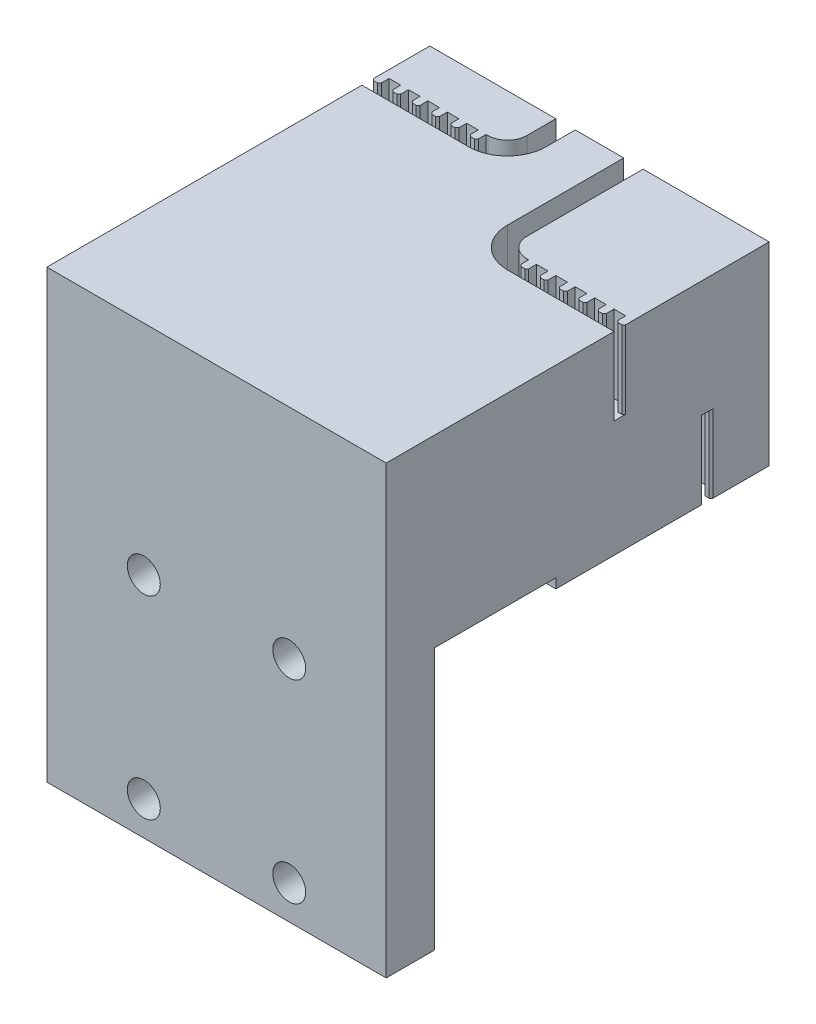
from build123d import *

# Parameters (mm, degrees)
SKETCH1_W           = 35
SKETCH1_H           = 22
BOSS_EXTRUDE1_DEPTH = 20
CUT_EXTRUDE1_DEPTH  = 8
CUT_EXTRUDE2_DEPTH  = 8
BOSS_EXTRUDE2_DEPTH = 8
BOSS_EXTRUDE4_DEPTH = 8
SKETCH9_W           = 35
SKETCH9_H           = 19
BOSS_EXTRUDE5_DEPTH = 12.5
SKETCH11_W          = 35
SKETCH11_H          = 46
BOSS_EXTRUDE6_DEPTH = 5
SKETCH12_R          = 1.7
CUT_EXTRUDE3_DEPTH  = 5


with BuildPart() as part:
    # Sketch1 → Boss-Extrude1 (new body)
    with BuildSketch(Plane(origin=(0, 0, 0), x_dir=(1, 0, 0), z_dir=(0, 1, 0))):
        with Locations((17.5, 11)):
            Rectangle(SKETCH1_W, SKETCH1_H)
    extrude(amount=BOSS_EXTRUDE1_DEPTH)

    # Sketch2 → Cut-Extrude1 (cut)
    with BuildSketch(Plane(origin=(0, 20, 0), x_dir=(1, 0, 0), z_dir=(0, 1, 0))):
        with BuildLine():
            Line((0, 15), (11, 15))
            ThreePointArc((11, 15), (13.828427125, 16.171572875), (15, 19))
            Line((15, 19), (15, 22))
            Line((15, 22), (13, 22))
            Line((13, 22), (13, 19))
            ThreePointArc((13, 19), (12.414213562, 17.585786438), (11, 17))
            Line((11, 17), (0, 17))
            Line((0, 17), (0, 15))
        make_face()
        with BuildLine():
            Line((35, 6), (24, 6))
            ThreePointArc((24, 6), (21.171572875, 7.171572875), (20, 10))
            Line((20, 10), (20, 22))
            Line((20, 22), (22, 22))
            Line((22, 22), (22, 10))
            ThreePointArc((22, 10), (22.585786438, 8.585786438), (24, 8))
            Line((24, 8), (35, 8))
            Line((35, 8), (35, 6))
        make_face()
    extrude(amount=-CUT_EXTRUDE1_DEPTH, mode=Mode.SUBTRACT)

    # Sketch5 → Cut-Extrude2 (cut)
    with BuildSketch(Plane(origin=(0, 0, 0), x_dir=(-1, 0, 0), z_dir=(0, -1, 0))):
        with BuildLine():
            Line((-35, 15), (-24, 15))
            ThreePointArc((-24, 15), (-21.171572875, 16.171572875), (-20, 19))
            Line((-20, 19), (-20, 22))
            Line((-20, 22), (-22, 22))
            Line((-22, 22), (-22, 19))
            ThreePointArc((-22, 19), (-22.585786438, 17.585786438), (-24, 17))
            Line((-24, 17), (-35, 17))
            Line((-35, 17), (-35, 15))
        make_face()
        with BuildLine():
            Line((0, 6), (-11, 6))
            ThreePointArc((-11, 6), (-13.828427125, 7.171572875), (-15, 10))
            Line((-15, 10), (-15, 22))
            Line((-15, 22), (-13, 22))
            Line((-13, 22), (-13, 10))
            ThreePointArc((-13, 10), (-12.414213562, 8.585786438), (-11, 8))
            Line((-11, 8), (0, 8))
            Line((0, 8), (0, 6))
        make_face()
    extrude(amount=-CUT_EXTRUDE2_DEPTH, mode=Mode.SUBTRACT)

    # Sketch6 → Boss-Extrude2 (add)
    with BuildSketch(Plane(origin=(0, 20, 0), x_dir=(1, 0, 0), z_dir=(0, 1, 0))):
        Polygon((0.2, 16), (0, 16.2), (0, 17), (0.8, 17), (0.8, 16.2), (0.6, 16), align=None)
        Polygon((2.2, 16), (2, 16.2), (2, 17), (2.8, 17), (2.8, 16.2), (2.6, 16), align=None)
        Polygon((4.2, 16), (4, 16.2), (4, 17), (4.8, 17), (4.8, 16.2), (4.6, 16), align=None)
        Polygon((6.2, 16), (6, 16.2), (6, 17), (6.8, 17), (6.8, 16.2), (6.6, 16), align=None)
        Polygon((8.2, 16), (8, 16.2), (8, 17), (8.8, 17), (8.8, 16.2), (8.6, 16), align=None)
        Polygon((10.2, 16), (10, 16.2), (10, 17), (10.8, 17), (10.8, 16.2), (10.6, 16), align=None)
        Polygon((34.4, 7), (34.2, 7.2), (34.2, 8), (35, 8), (35, 7.2), (34.8, 7), align=None)
        Polygon((32.4, 7), (32.2, 7.2), (32.2, 8), (33, 8), (33, 7.2), (32.8, 7), align=None)
        Polygon((30.4, 7), (30.2, 7.2), (30.2, 8), (31, 8), (31, 7.2), (30.8, 7), align=None)
        Polygon((28.4, 7), (28.2, 7.2), (28.2, 8), (29, 8), (29, 7.2), (28.8, 7), align=None)
        Polygon((26.4, 7), (26.2, 7.2), (26.2, 8), (27, 8), (27, 7.2), (26.8, 7), align=None)
        Polygon((24.4, 7), (24.2, 7.2), (24.2, 8), (25, 8), (25, 7.2), (24.8, 7), align=None)
    extrude(amount=-BOSS_EXTRUDE2_DEPTH)

    # Sketch8 → Boss-Extrude4 (add)
    with BuildSketch(Plane.XZ):
        Polygon((35, -17), (35, -16.2), (34.8, -16), (34.4, -16), (34.2, -16.2), (34.2, -17), align=None)
        Polygon((33, -17), (33, -16.2), (32.8, -16), (32.4, -16), (32.2, -16.2), (32.2, -17), align=None)
        Polygon((31, -17), (31, -16.2), (30.8, -16), (30.4, -16), (30.2, -16.2), (30.2, -17), align=None)
        Polygon((29, -17), (29, -16.2), (28.8, -16), (28.4, -16), (28.2, -16.2), (28.2, -17), align=None)
        Polygon((27, -17), (27, -16.2), (26.8, -16), (26.4, -16), (26.2, -16.2), (26.2, -17), align=None)
        Polygon((25, -17), (25, -16.2), (24.8, -16), (24.4, -16), (24.2, -16.2), (24.2, -17), align=None)
        Polygon((0.8, -8), (0.8, -7.2), (0.6, -7), (0.2, -7), (0, -7.2), (0, -8), align=None)
        Polygon((2.8, -8), (2.8, -7.2), (2.6, -7), (2.2, -7), (2, -7.2), (2, -8), align=None)
        Polygon((4.8, -8), (4.8, -7.2), (4.6, -7), (4.2, -7), (4, -7.2), (4, -8), align=None)
        Polygon((6.8, -8), (6.8, -7.2), (6.6, -7), (6.2, -7), (6, -7.2), (6, -8), align=None)
        Polygon((8.8, -8), (8.8, -7.2), (8.6, -7), (8.2, -7), (8, -7.2), (8, -8), align=None)
        Polygon((10.8, -8), (10.8, -7.2), (10.6, -7), (10.2, -7), (10, -7.2), (10, -8), align=None)
    extrude(amount=-BOSS_EXTRUDE4_DEPTH)

    # Sketch9 → Boss-Extrude5 (add)
    with BuildSketch(Plane.XY):
        with Locations((17.5, 10.5)):
            Rectangle(SKETCH9_W, SKETCH9_H)
    extrude(amount=BOSS_EXTRUDE5_DEPTH)

    # Sketch11 → Boss-Extrude6 (add)
    with BuildSketch(Plane.XY.offset(12.5)):
        with Locations((17.5, -3)):
            Rectangle(SKETCH11_W, SKETCH11_H)
    extrude(amount=BOSS_EXTRUDE6_DEPTH)

    # Sketch12 → Cut-Extrude3 (cut)
    with BuildSketch(Plane.XY.offset(17.5)):
        with Locations((10, -2.5)):
            Circle(SKETCH12_R)
        with Locations((25, -2.5)):
            Circle(SKETCH12_R)
        with Locations((25, -22.5)):
            Circle(SKETCH12_R)
        with Locations((10, -22.5)):
            Circle(SKETCH12_R)
    extrude(amount=-CUT_EXTRUDE3_DEPTH, mode=Mode.SUBTRACT)


solid = part.part
